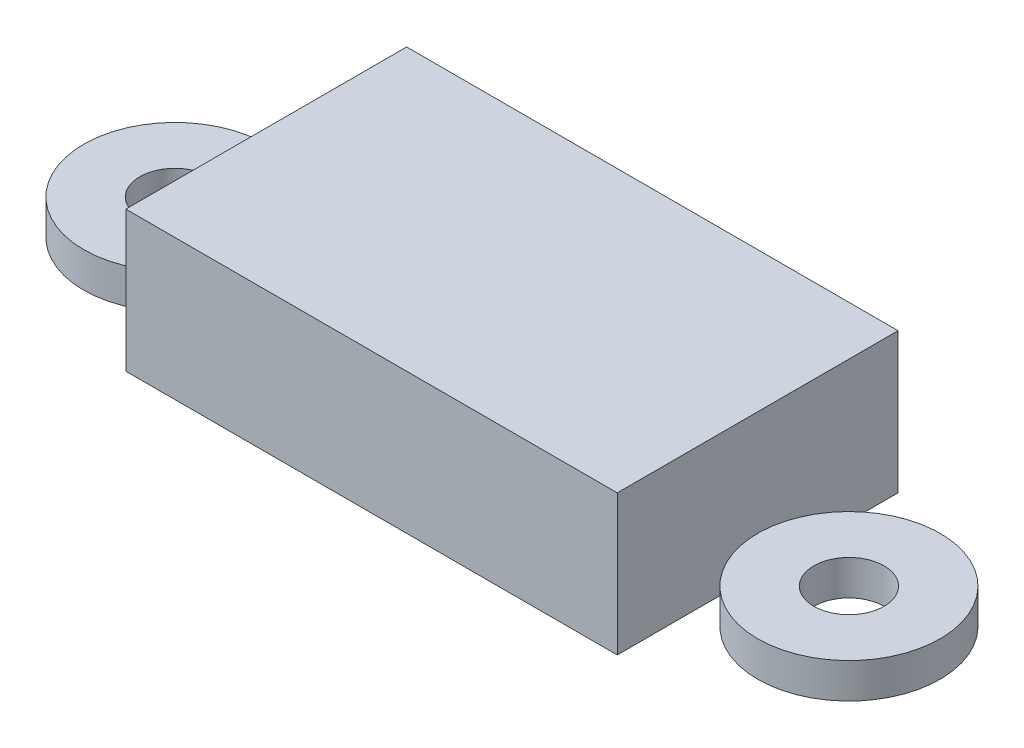
from build123d import *

# Parameters (mm, degrees)
EXTRUDE_1_DEPTH     = 20
SKETCH_3_W          = 66.20559445
SKETCH_3_H          = 15.93838385
CUT_EXTRUDE_2_DEPTH = 30
SKETCH_1_8_R        = 13
SKETCH_1_8_R_2      = 5
EXTRUDE_5_DEPTH     = 5
SKETCH_1_9_R        = 13
SKETCH_1_9_R_2      = 5
EXTRUDE_6_DEPTH     = 5


with BuildPart() as part:
    # 草图1 → 凸台-拉伸1 (new body)
    with BuildSketch(Plane(origin=(0, 0, 0), x_dir=(1, 0, 0), z_dir=(0, 1, 0))):
        Polygon((-35, -20), (35, -20), (35, -1.9e-08), (35, 20), (-35, 20), (-35, 0), align=None)
    extrude(amount=EXTRUDE_1_DEPTH)

    # 草图3 → 切除-拉伸2 (cut)
    with BuildSketch(Plane(origin=(0, 0, -20), x_dir=(-1, 0, 0), z_dir=(0, 0, -1))):
        with Locations((0, 9.952430017)):
            Rectangle(SKETCH_3_W, SKETCH_3_H)
    extrude(amount=-CUT_EXTRUDE_2_DEPTH, mode=Mode.SUBTRACT)


with BuildPart() as body_2:
    # 草图1<8> → 凸台-拉伸5 (new body)
    with BuildSketch(Plane(origin=(0, 0, 0), x_dir=(1, 0, 0), z_dir=(0, 1, 0))):
        with Locations((48, 0)):
            Circle(SKETCH_1_8_R)
        with Locations((48, 0)):
            Circle(SKETCH_1_8_R_2, mode=Mode.SUBTRACT)
    extrude(amount=EXTRUDE_5_DEPTH)


with BuildPart() as body_3:
    # 草图1<9> → 凸台-拉伸6 (new body)
    with BuildSketch(Plane(origin=(0, 0, 0), x_dir=(1, 0, 0), z_dir=(0, 1, 0))):
        with Locations((-48, 0)):
            Circle(SKETCH_1_9_R)
        with Locations((-48, 0)):
            Circle(SKETCH_1_9_R_2, mode=Mode.SUBTRACT)
    extrude(amount=EXTRUDE_6_DEPTH)


solid = Compound([part.part, body_2.part, body_3.part])
